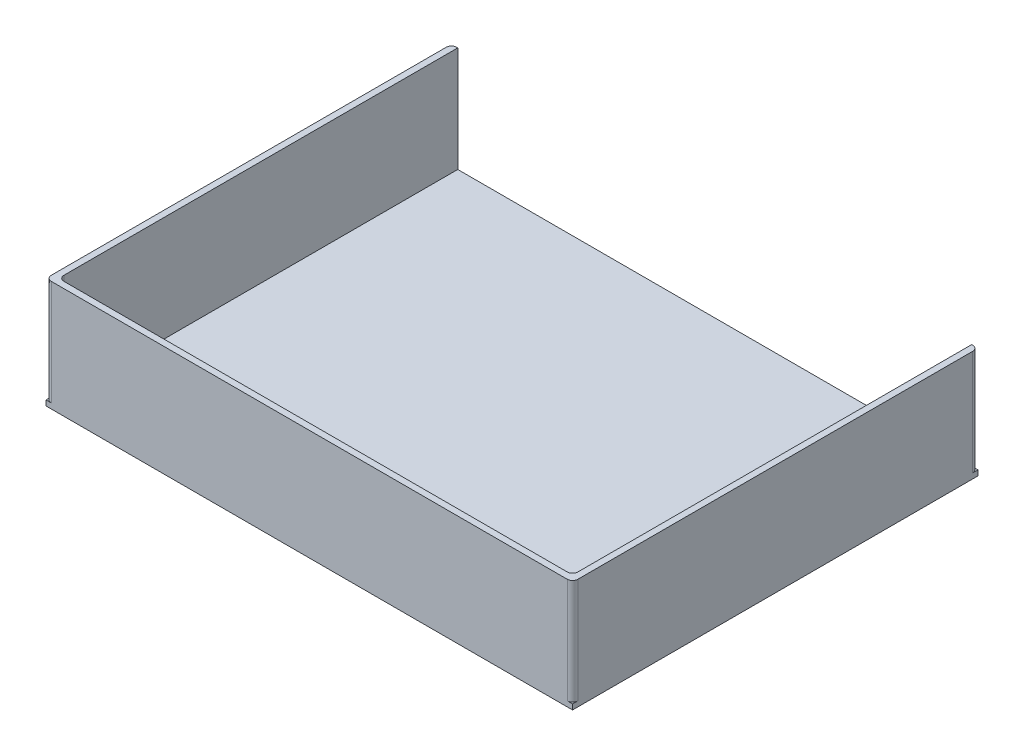
from build123d import *

# Parameters (mm, degrees)
CROQUIS1_W              = 500
CROQUIS1_H              = 385
SALIENTE_EXTRUIR1_DEPTH = 5
SALIENTE_EXTRUIR2_DEPTH = 100


with BuildPart() as part:
    # Croquis1 → Saliente-Extruir1 (new body)
    with BuildSketch(Plane(origin=(0, 0, 0), x_dir=(1, 0, 0), z_dir=(0, 1, 0))):
        Rectangle(CROQUIS1_W, CROQUIS1_H)
    extrude(amount=SALIENTE_EXTRUIR1_DEPTH)

    # Croquis2 → Saliente-Extruir2 (add)
    with BuildSketch(Plane(origin=(0, 5, 0), x_dir=(1, 0, 0), z_dir=(0, 1, 0))):
        with BuildLine():
            Line((-244, 186.5), (-244, -181.5))
            ThreePointArc((-244, -181.5), (-242.535533906, -185.035533906), (-239, -186.5))
            Line((-239, -186.5), (239, -186.5))
            ThreePointArc((239, -186.5), (242.535533906, -185.035533906), (244, -181.5))
            Line((244, -181.5), (244, 186.5))
            Line((244, 186.5), (244, 192.5))
            Line((244, 192.5), (245, 192.5))
            ThreePointArc((245, 192.5), (248.535533906, 191.035533906), (250, 187.5))
            Line((250, 187.5), (250, -187.5))
            ThreePointArc((250, -187.5), (248.535533906, -191.035533906), (245, -192.5))
            Line((245, -192.5), (-245, -192.5))
            ThreePointArc((-245, -192.5), (-248.535533906, -191.035533906), (-250, -187.5))
            Line((-250, -187.5), (-250, 187.5))
            ThreePointArc((-250, 187.5), (-248.535533906, 191.035533906), (-245, 192.5))
            Line((-245, 192.5), (-244, 192.5))
            Line((-244, 192.5), (-244, 186.5))
        make_face()
    extrude(amount=SALIENTE_EXTRUIR2_DEPTH)


solid = part.part
